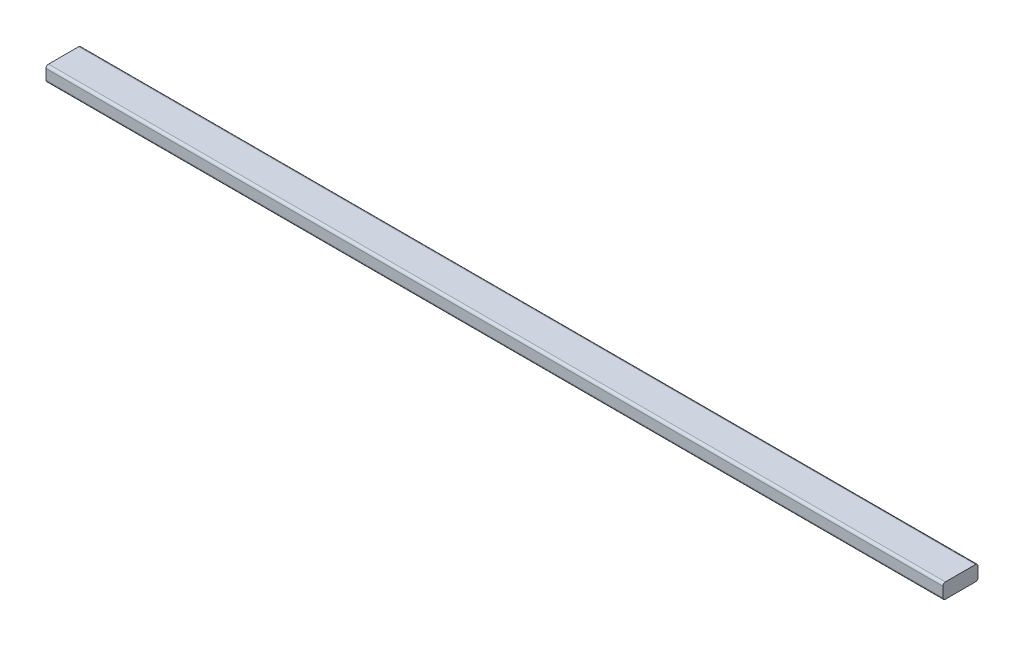
from build123d import *

# Parameters (mm, degrees)
BOSS_EXTRUDE1_DEPTH = 1134.11


with BuildPart() as part:
    # Sketch1 → Boss-Extrude1 (new body, symmetric)
    with BuildSketch(Plane(origin=(0, 0, 0), x_dir=(0, 0, -1), z_dir=(1, 0, 0))):
        with BuildLine():
            Line((-38.1, -19.05), (38.1, -19.05))
            ThreePointArc((38.1, -19.05), (42.590128061, -17.190128061), (44.45, -12.7))
            Line((44.45, -12.7), (44.45, 12.7))
            ThreePointArc((44.45, 12.7), (42.590128061, 17.190128061), (38.1, 19.05))
            Line((38.1, 19.05), (-38.1, 19.05))
            ThreePointArc((-38.1, 19.05), (-42.590128061, 17.190128061), (-44.45, 12.7))
            Line((-44.45, 12.7), (-44.45, -12.7))
            ThreePointArc((-44.45, -12.7), (-42.590128061, -17.190128061), (-38.1, -19.05))
        make_face()
    extrude(amount=BOSS_EXTRUDE1_DEPTH, both=True)


solid = part.part
